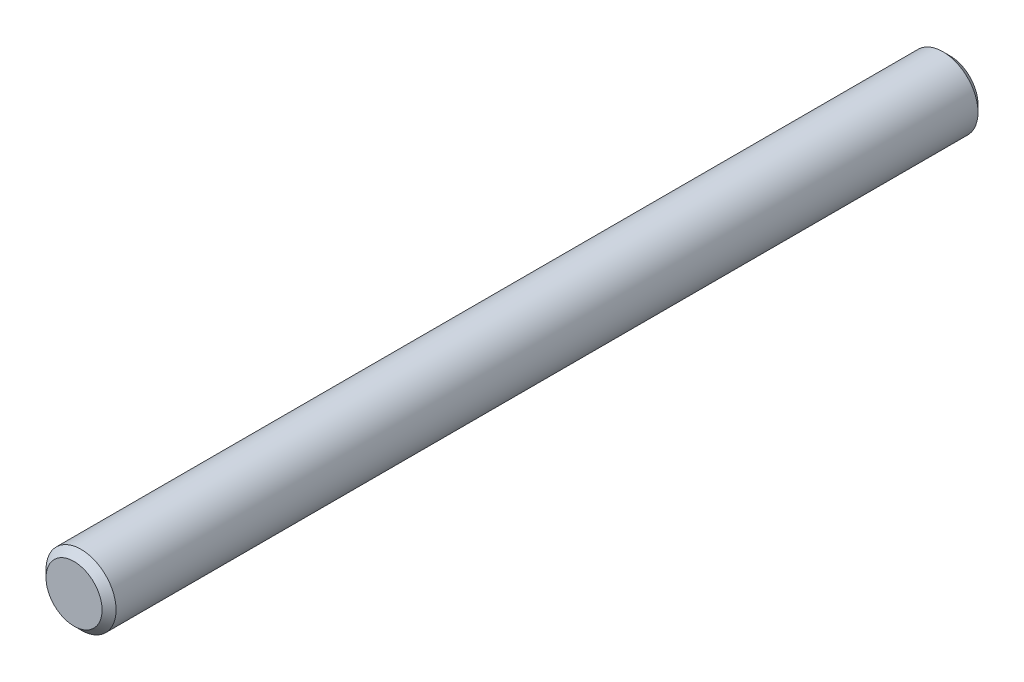
from build123d import *

# Parameters (mm, degrees)
SKETCH1_R               = 4
EXTRUDE1_DEPTH          = 100
CHAMFER1_SIZE           = 0.8
SKETCH2_W               = 103.982490854
SKETCH2_H               = 8.719679173
CUT_EXTRUDE1_DEPTH      = 5
CUT_EXTRUDE1_DEPTH_BACK = 5
CHAMFER2_SIZE           = 0.8


with BuildPart() as part:
    # Sketch1 → Extrude1 (new body, symmetric)
    with BuildSketch(Plane.XY):
        Circle(SKETCH1_R)
    extrude(amount=EXTRUDE1_DEPTH, both=True)

    # Chamfer1
    chamfer1_edges = [part.edges().sort_by_distance(p)[0] for p in [
        (-4, 0, -100),
        (-4, 0, 100),
    ]]
    chamfer(chamfer1_edges, length=CHAMFER1_SIZE)

    # Sketch2 → Cut-Extrude1 (cut, two sides)
    with BuildSketch(Plane(origin=(0, 0, 0), x_dir=(0, 0, -1), z_dir=(1, 0, 0))) as cut_extrude1_sk:
        with Locations((51.991245427, -0.359839587)):
            Rectangle(SKETCH2_W, SKETCH2_H)
    extrude(amount=CUT_EXTRUDE1_DEPTH, mode=Mode.SUBTRACT)
    extrude(cut_extrude1_sk.sketch, amount=-CUT_EXTRUDE1_DEPTH_BACK, mode=Mode.SUBTRACT)

    # Chamfer2
    chamfer2_edges = [part.edges().sort_by_distance(p)[0] for p in [
        (-4, 0, 0),
    ]]
    chamfer(chamfer2_edges, length=CHAMFER2_SIZE)


solid = part.part
